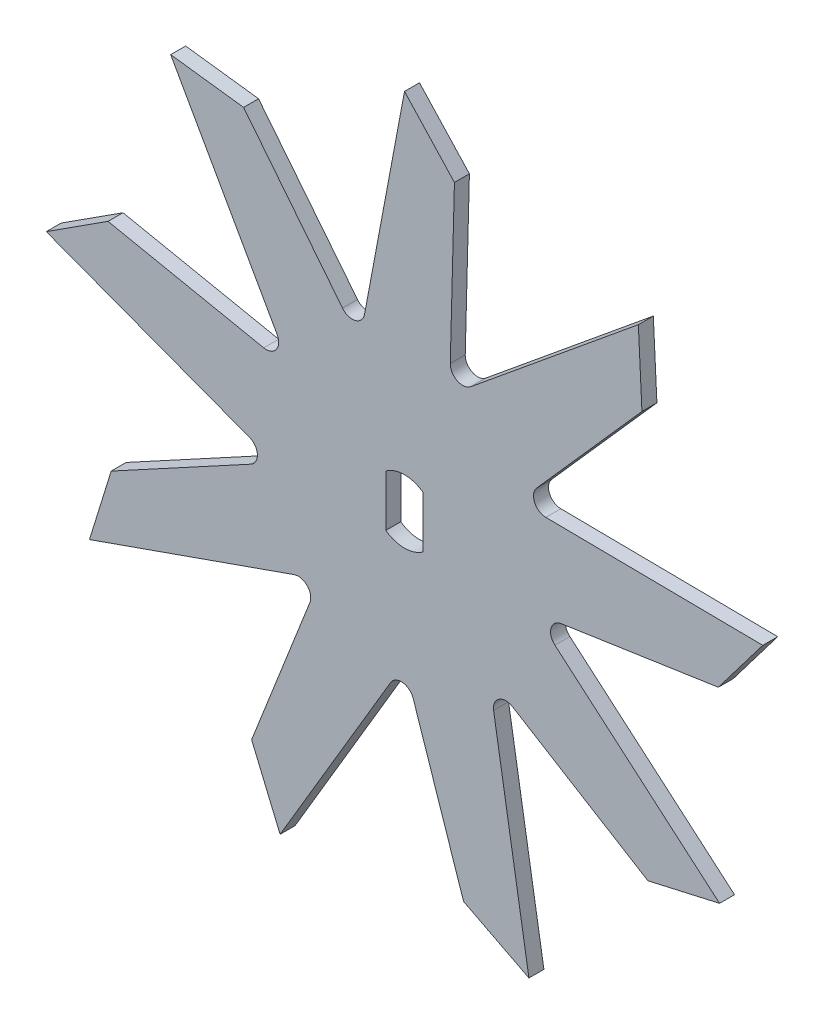
from build123d import *

# Parameters (mm, degrees)
BOSS_EXTRU_1_DEPTH = 6


with BuildPart() as part:
    # Esquisse1 → Boss.-Extru.1 (new body)
    with BuildSketch(Plane.XY):
        with BuildLine():
            Line((-16.024411517, 60.322401795), (0, 145.75))
            Line((0, 145.75), (20, 124.149355617))
            Line((20, 124.149355617), (18.328771536, 60.506183401))
            ThreePointArc((18.328771536, 60.506183401), (21.130165565, 55.883417087), (26.499081063, 56.509933866))
            Line((26.499081063, 56.509933866), (93.686294112, 111.650977585))
            Line((93.686294112, 111.650977585), (95.122556403, 82.248171793))
            Line((95.122556403, 82.248171793), (52.933278584, 34.568918325))
            ThreePointArc((52.933278584, 34.568918325), (52.107814004, 29.226972506), (56.62335911, 26.255839844))
            Line((56.62335911, 26.255839844), (143.535730002, 25.309221895))
            Line((143.535730002, 25.309221895), (125.736211496, 1.862154301))
            Line((125.736211496, 1.862154301), (62.769716295, -7.543527827))
            ThreePointArc((62.769716295, -7.543527827), (58.703637157, -11.105097332), (60.25293813, -16.283653443))
            Line((60.25293813, -16.283653443), (126.223202602, -72.875))
            Line((126.223202602, -72.875), (97.516495827, -79.395185884))
            Line((97.516495827, -79.395185884), (43.235506143, -46.126273471))
            ThreePointArc((43.235506143, -46.126273471), (37.831376065, -46.240968709), (35.689497763, -51.203844311))
            Line((35.689497763, -51.203844311), (49.84943589, -136.96019948))
            Line((49.84943589, -136.96019948), (23.667727986, -123.502636215))
            Line((23.667727986, -123.502636215), (3.470922159, -63.126023122))
            ThreePointArc((3.470922159, -63.126023122), (-0.742606336, -59.740176916), (-5.573455253, -62.165187359))
            Line((-5.573455253, -62.165187359), (-49.84943589, -136.96019948))
            Line((-49.84943589, -136.96019948), (-61.255432817, -109.821830482))
            Line((-61.255432817, -109.821830482), (-37.917744879, -50.588404986))
            ThreePointArc((-37.917744879, -50.588404986), (-38.969114979, -45.286292406), (-44.228526613, -44.038748352))
            Line((-44.228526613, -44.038748352), (-126.223202602, -72.875))
            Line((-126.223202602, -72.875), (-117.516495827, -44.754169733))
            Line((-117.516495827, -44.754169733), (-61.564277679, -14.37990993))
            ThreePointArc((-61.564277679, -14.37990993), (-58.961541631, -9.642448378), (-62.188578826, -5.306089555))
            Line((-62.188578826, -5.306089555), (-143.535730002, 25.309221895))
            Line((-143.535730002, 25.309221895), (-118.790284389, 41.254464422))
            Line((-118.790284389, 41.254464422), (-56.404200742, 28.557104797))
            ThreePointArc((-56.404200742, 28.557104797), (-51.365207668, 30.51320441), (-51.049903857, 35.909347515))
            Line((-51.049903857, 35.909347515), (-93.686294112, 111.650977585))
            Line((-93.686294112, 111.650977585), (-64.480778678, 107.959676181))
            Line((-64.480778678, 107.959676181), (-24.851971415, 58.131932813))
            ThreePointArc((-24.851971415, 58.131932813), (-19.734522177, 56.391389738), (-16.024411517, 60.322401795))
        make_face()
        with BuildLine():
            Line((-7.5, 10.310795314), (-7.5, -10.310795314))
            ThreePointArc((-7.5, -10.310795314), (0, -12.75), (7.5, -10.310795314))
            Line((7.5, -10.310795314), (7.5, 10.310795314))
            ThreePointArc((7.5, 10.310795314), (0, 12.75), (-7.5, 10.310795314))
        make_face(mode=Mode.SUBTRACT)
    extrude(amount=BOSS_EXTRU_1_DEPTH)


solid = part.part
